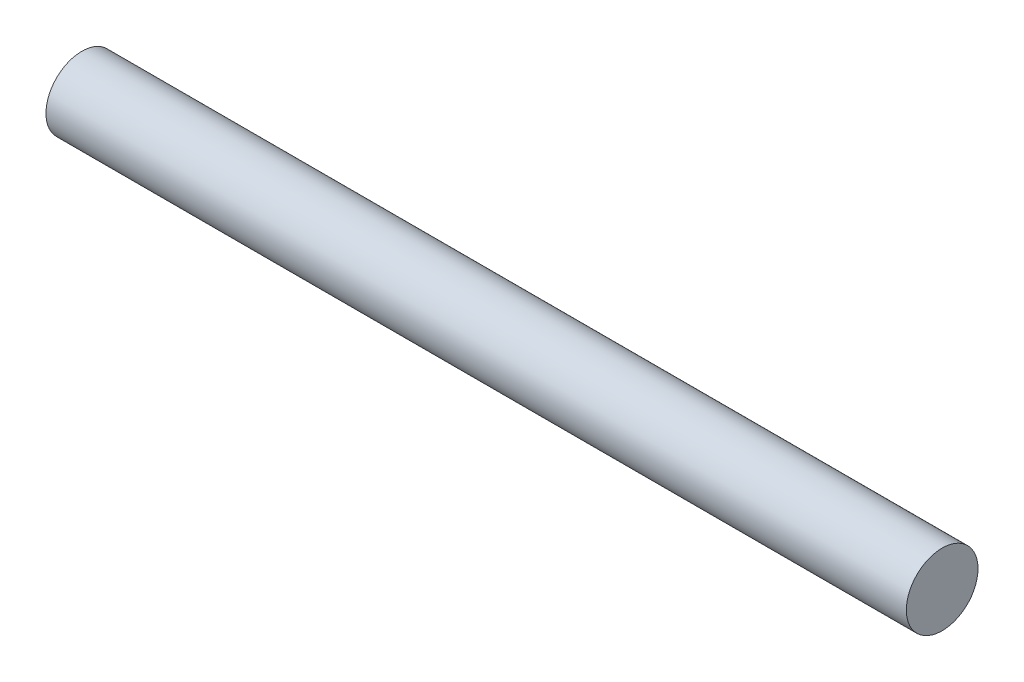
from build123d import *

# Parameters (mm, degrees)
SKETCH1_R           = 1.5875
BOSS_EXTRUDE1_DEPTH = 19.05


with BuildPart() as part:
    # Sketch1 → Boss-Extrude1 (new body, symmetric)
    with BuildSketch(Plane(origin=(0, 0, 0), x_dir=(0, 0, -1), z_dir=(1, 0, 0))):
        Circle(SKETCH1_R)
    extrude(amount=BOSS_EXTRUDE1_DEPTH, both=True)


solid = part.part
